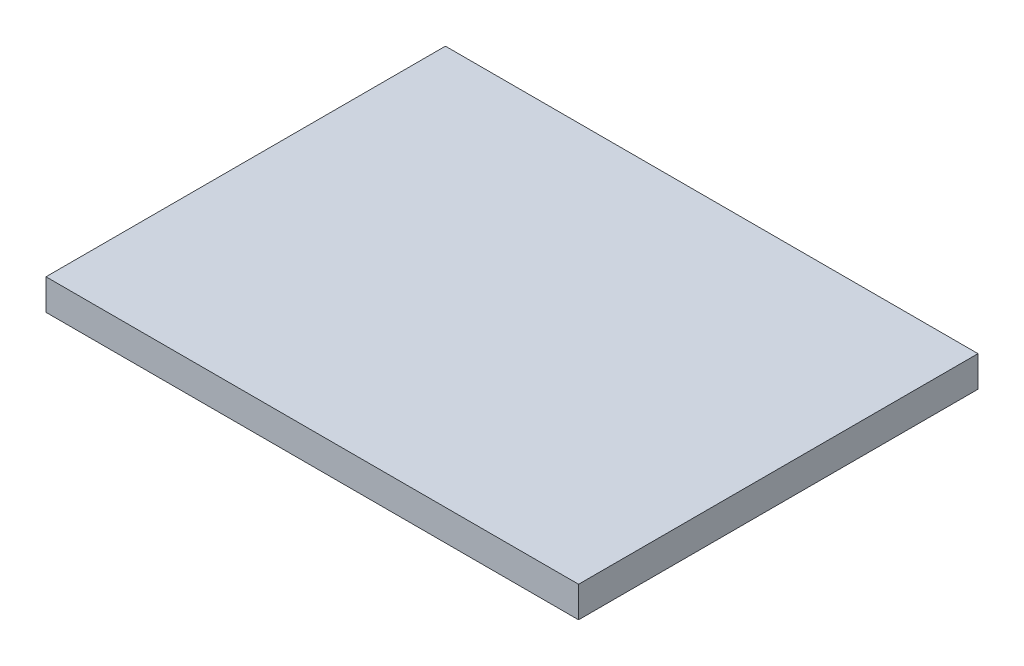
from build123d import *

# Parameters (mm, degrees)
SKETCH1_W           = 42.667
SKETCH1_H           = 32
EXTRUDE1_DEPTH      = 2
SKETCH2_OUTSIDE_W   = 55.341
SKETCH2_OUTSIDE_H   = 44.674
SKETCH2_OUTSIDE_W_2 = 34.544
SKETCH2_OUTSIDE_H_2 = 25.908
CUT_EXTRUDE3_DEPTH  = 3


with BuildPart() as part:
    # Sketch1 → Extrude1 (new body)
    with BuildSketch(Plane(origin=(0, 0, 0), x_dir=(1, 0, 0), z_dir=(0, 1, 0))):
        with Locations((21.3335, -16)):
            Rectangle(SKETCH1_W, SKETCH1_H)
    extrude(amount=EXTRUDE1_DEPTH)

    # Sketch2 outside → Cut-Extrude3 (cut, through all)
    with BuildSketch(Plane(origin=(0, 2, 0), x_dir=(-1, 0, 0), z_dir=(0, 1, 0))):
        with Locations((-21.3335, 16)):
            Rectangle(SKETCH2_OUTSIDE_W, SKETCH2_OUTSIDE_H)
        with Locations((-21.3335, 16)):
            Rectangle(SKETCH2_OUTSIDE_W_2, SKETCH2_OUTSIDE_H_2, mode=Mode.SUBTRACT)
    extrude(amount=-CUT_EXTRUDE3_DEPTH, mode=Mode.SUBTRACT)


solid = part.part
